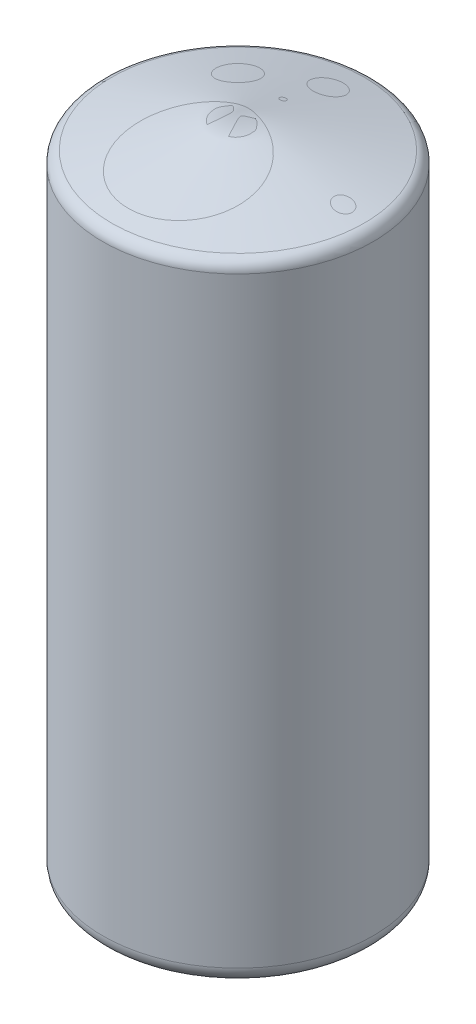
from build123d import *


with BuildPart() as part:
    # Skizze1 → Rotation4 (revolve)
    with BuildSketch(Plane.XY, mode=Mode.PRIVATE) as rotation4_sk:
        with BuildLine():
            Line((-75, 27.29776757), (-413.811107883, 150.614925878))
            ThreePointArc((-413.811107883, 150.614925878), (-440.053362436, 170.751316022), (-450, 202.298020021))
            Line((-450, 202.298020021), (-450, 2202.298020021))
            ThreePointArc((-450, 2202.298020021), (-441.734133612, 2226.648477182), (-420.352761804, 2240.935053073))
            Line((-420.352761804, 2240.935053073), (0, 2353.568236134))
            Line((0, 2353.568236134), (0, 2350.980045683))
            Line((0, 2350.980045683), (-419.705714191, 2238.520238507))
            ThreePointArc((-419.705714191, 2238.520238507), (-439.750750261, 2225.126573609), (-447.5, 2202.298020021))
            Line((-447.5, 2202.298020021), (-447.5, 202.298020021))
            ThreePointArc((-447.5, 202.298020021), (-438.005482325, 172.185257113), (-412.956057525, 152.96415743))
            Line((-412.956057525, 152.96415743), (-75, 29.958212001))
            Line((-75, 29.958212001), (-75, 27.29776757))
        make_face()
    revolve(rotation4_sk.sketch.rotate(Axis((0, 0, 0), (0, 1, 0)), 270), axis=Axis((0, 0, 0), (0, 1, 0)))  # turned: the seam where the file's is


solid = part.part
